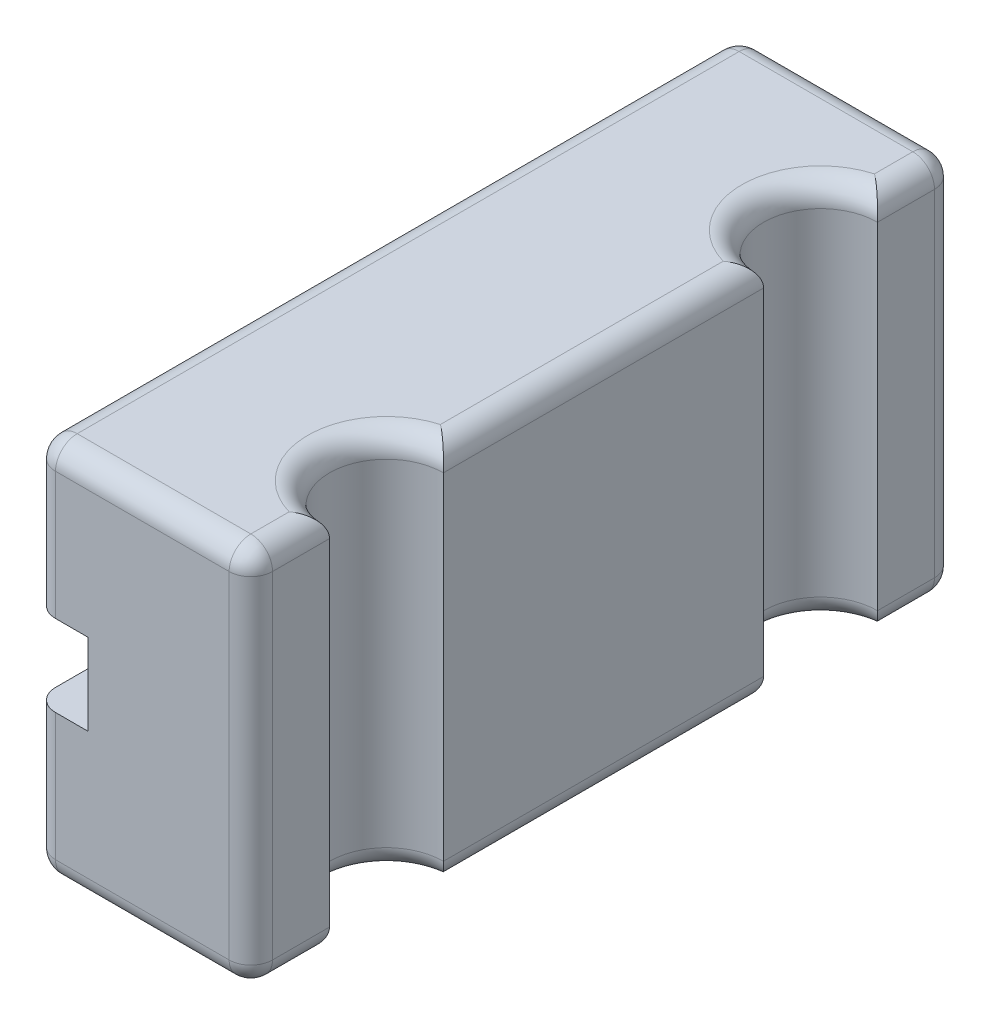
from build123d import *

# Parameters (mm, degrees)
BOSS_EXTRUDE1_DEPTH = 17.5
FILLET1_R           = 2
SKETCH3_W           = 5
SKETCH3_H           = 7.5
CUT_EXTRUDE1_DEPTH  = 66


with BuildPart() as part:
    # Sketch2 → Boss-Extrude1 (new body, symmetric)
    with BuildSketch(Plane(origin=(0, 0, 0), x_dir=(1, 0, 0), z_dir=(0, 1, 0))):
        with BuildLine():
            Line((5.25, 14.75), (5.25, -14.75))
            ThreePointArc((5.25, -14.75), (0, -20), (5.25, -25.25))
            Line((5.25, -25.25), (5.25, -32.5))
            Line((5.25, -32.5), (-14.75, -32.5))
            Line((-14.75, -32.5), (-14.75, 32.5))
            Line((-14.75, 32.5), (5.25, 32.5))
            Line((5.25, 32.5), (5.25, 25.25))
            ThreePointArc((5.25, 25.25), (0, 20), (5.25, 14.75))
        make_face()
    extrude(amount=BOSS_EXTRUDE1_DEPTH, both=True)

    # Fillet1
    fillet1_edges = [part.edges().sort_by_distance(p)[0] for p in [
        (-14.75, -17.5, 0),
        (-4.75, -17.5, -32.5),
        (5.25, -17.5, -28.875),
        (0, -17.5, -20),
        (-4.75, 17.5, -32.5),
        (5.25, 0, 32.5),
        (-14.75, 0, 32.5),
        (-14.75, 0, -32.5),
        (5.25, 0, -32.5),
        (-14.75, 17.5, 0),
        (-4.75, 17.5, 32.5),
        (5.25, 17.5, 28.875),
        (0, 17.5, 20),
        (5.25, 17.5, 0),
        (0, 17.5, -20),
        (5.25, -17.5, 0),
        (5.25, 17.5, -28.875),
        (0, -17.5, 20),
        (5.25, -17.5, 28.875),
        (-4.75, -17.5, 32.5),
    ]]
    fillet(fillet1_edges, radius=FILLET1_R)

    # Sketch3 → Cut-Extrude1 (cut, through all)
    with BuildSketch(Plane.XY.offset(32.5)):
        with Locations((-12.25, 0)):
            Rectangle(SKETCH3_W, SKETCH3_H)
    extrude(amount=-CUT_EXTRUDE1_DEPTH, mode=Mode.SUBTRACT)


solid = part.part
